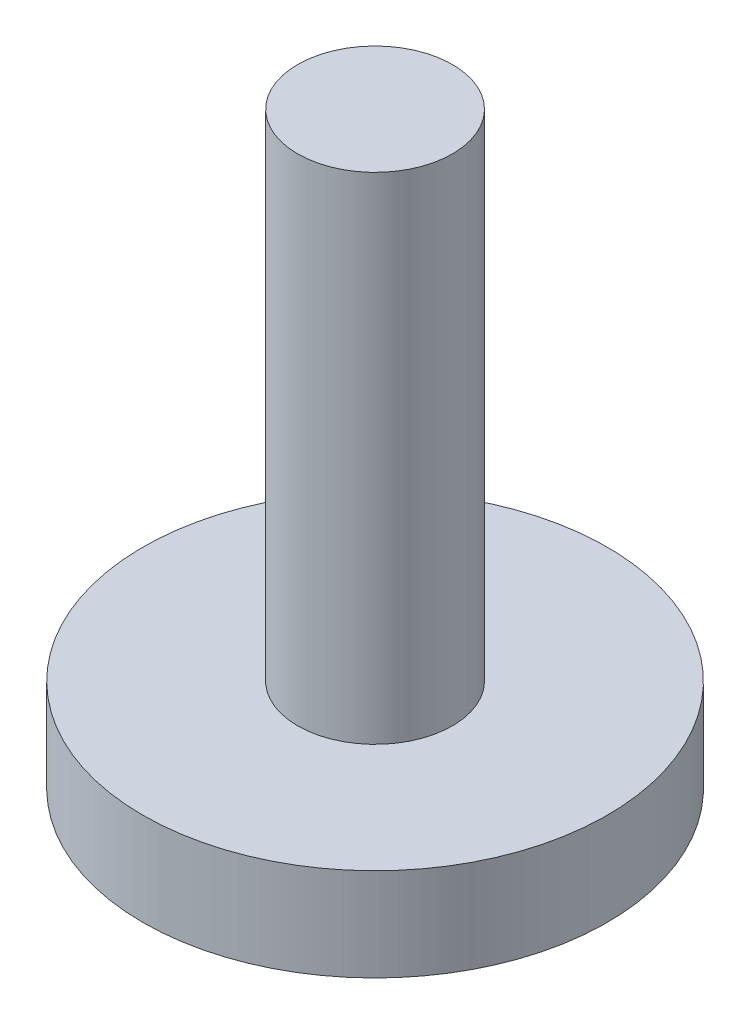
from build123d import *

# Parameters (mm, degrees)
SKETCH2_R           = 7.5
BOSS_EXTRUDE1_DEPTH = 3
SKETCH5_R           = 2.5
BOSS_EXTRUDE2_DEPTH = 16


with BuildPart() as part:
    # Sketch2 → Boss-Extrude1 (new body)
    with BuildSketch(Plane(origin=(0, 0, 0), x_dir=(1, 0, 0), z_dir=(0, 1, 0))):
        Circle(SKETCH2_R)
    extrude(amount=BOSS_EXTRUDE1_DEPTH)

    # Sketch5 → Boss-Extrude2 (add)
    with BuildSketch(Plane(origin=(0, 3, 0), x_dir=(1, 0, 0), z_dir=(0, 1, 0))):
        Circle(SKETCH5_R)
    extrude(amount=BOSS_EXTRUDE2_DEPTH)


solid = part.part
